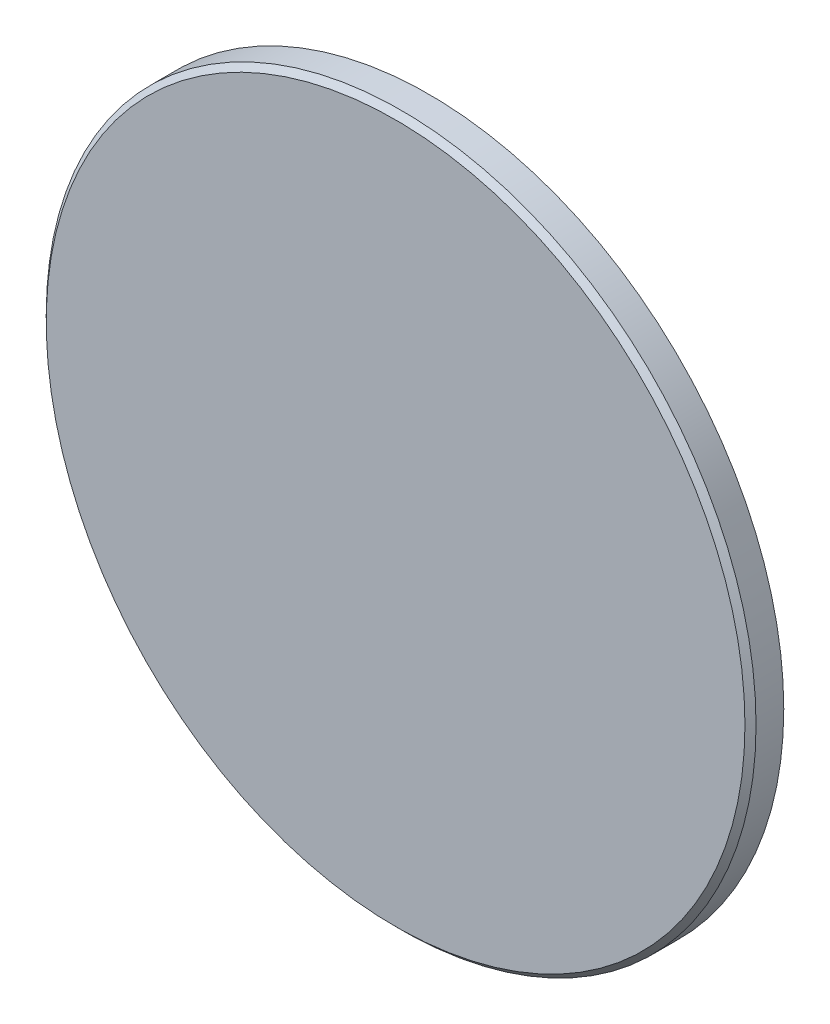
from build123d import *

# Parameters (mm, degrees)
SKETCH1_R           = 16
BOSS_EXTRUDE1_DEPTH = 1.5
CHAMFER1_SIZE       = 0.25


with BuildPart() as part:
    # Sketch1 → Boss-Extrude1 (new body)
    with BuildSketch(Plane.XY):
        Circle(SKETCH1_R)
    extrude(amount=BOSS_EXTRUDE1_DEPTH)

    # Chamfer1
    chamfer1_edges = [part.edges().sort_by_distance(p)[0] for p in [
        (-16, 0, 1.5),
    ]]
    chamfer(chamfer1_edges, length=CHAMFER1_SIZE)


solid = part.part
